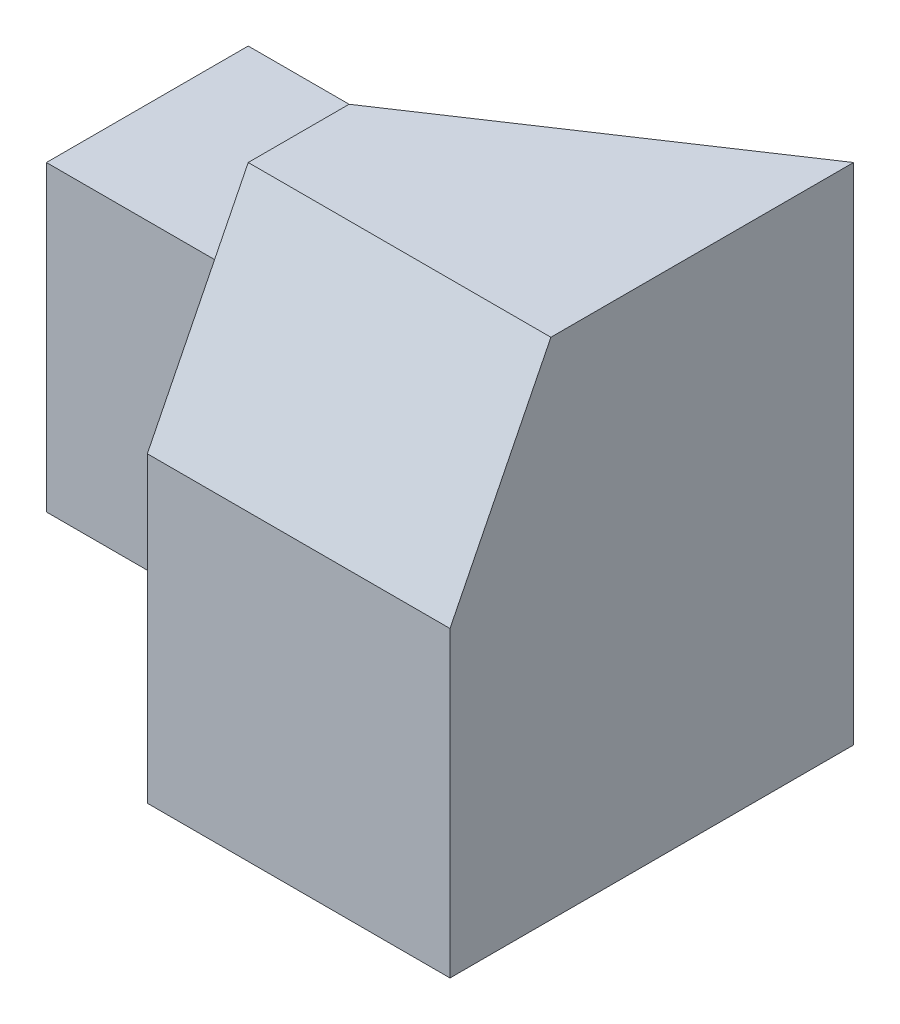
from build123d import *

# Parameters (mm, degrees)
SKETCH1_W           = 30
SKETCH1_H           = 25
BOSS_EXTRUDE1_DEPTH = 20
SKETCH2_W           = 15
SKETCH2_H           = 25
CUT_EXTRUDE1_DEPTH  = 10
SKETCH3_W           = 15
SKETCH3_H           = 10
CUT_EXTRUDE2_DEPTH  = 10
CUT_EXTRUDE3_DEPTH  = 20
CUT_EXTRUDE4_DEPTH  = 10


with BuildPart() as part:
    # Sketch1 → Boss-Extrude1 (new body)
    with BuildSketch(Plane.XY):
        with Locations((15, 12.5)):
            Rectangle(SKETCH1_W, SKETCH1_H)
    extrude(amount=BOSS_EXTRUDE1_DEPTH)

    # Sketch2 → Cut-Extrude1 (cut)
    with BuildSketch(Plane.XY.offset(20)):
        with Locations((7.5, 12.5)):
            Rectangle(SKETCH2_W, SKETCH2_H)
    extrude(amount=-CUT_EXTRUDE1_DEPTH, mode=Mode.SUBTRACT)

    # Sketch3 → Cut-Extrude2 (cut)
    with BuildSketch(Plane.XY.offset(10)):
        with Locations((7.5, 20)):
            Rectangle(SKETCH3_W, SKETCH3_H)
    extrude(amount=-CUT_EXTRUDE2_DEPTH, mode=Mode.SUBTRACT)

    # Sketch4 → Cut-Extrude3 (cut)
    with BuildSketch(Plane.ZY.offset(-15)):
        Polygon((15, 25), (20, 15), (20, 25), align=None)
    extrude(amount=-CUT_EXTRUDE3_DEPTH, mode=Mode.SUBTRACT)

    # Sketch5 → Cut-Extrude4 (cut)
    with BuildSketch(Plane(origin=(0, 25, 0), x_dir=(1, 0, 0), z_dir=(0, 1, 0))):
        Polygon((15, -10), (30, 0), (15, 0), align=None)
    extrude(amount=-CUT_EXTRUDE4_DEPTH, mode=Mode.SUBTRACT)


solid = part.part
